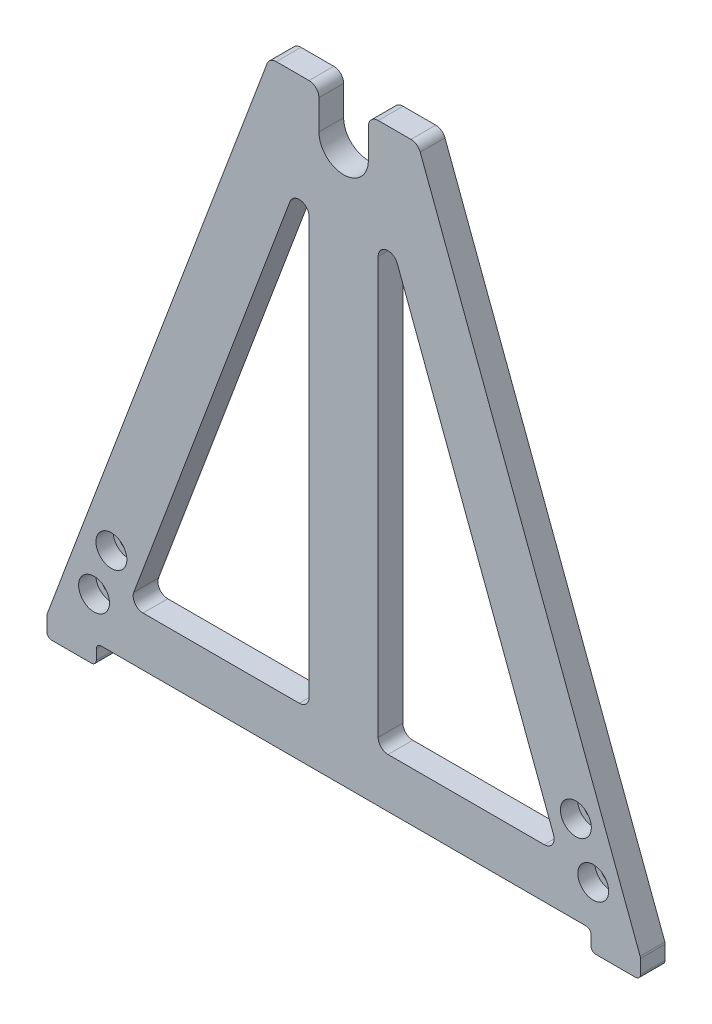
from build123d import *

# Parameters (mm, degrees)
BOSS_EXTRUDE1_DEPTH                            = 6.35
CUT_EXTRUDE1_DEPTH                             = 171.506664093
CUT_EXTRUDE2_DEPTH                             = 171.506664093
FILLET1_R                                      = 2.54
CBORE_FOR_8_SOCKET_HEAD_CAP_SCREW1_D           = 4.9149
CBORE_FOR_8_SOCKET_HEAD_CAP_SCREW1_CBORE_D     = 7.9375
CBORE_FOR_8_SOCKET_HEAD_CAP_SCREW1_CBORE_DEPTH = 4.4196


with BuildPart() as part:
    # Sketch1 → Boss-Extrude1 (new body)
    with BuildSketch(Plane.XY):
        with BuildLine():
            Line((-19.668054922, 150.751853542), (-76.119138056, 0.215631852))
            ThreePointArc((-76.119138056, 0.215631852), (-76.179621009, -0.003695416), (-76.2, -0.230294919))
            Line((-76.2, -0.230294919), (-76.2, -3.81))
            ThreePointArc((-76.2, -3.81), (-75.828025612, -4.708025612), (-74.93, -5.08))
            Line((-74.93, -5.08), (-64.77, -5.08))
            ThreePointArc((-64.77, -5.08), (-63.871974388, -4.708025612), (-63.5, -3.81))
            Line((-63.5, -3.81), (-63.5, -1.27))
            ThreePointArc((-63.5, -1.27), (-63.128025612, -0.371974388), (-62.23, 0))
            Line((-62.23, 0), (62.23, 0))
            ThreePointArc((62.23, 0), (63.128025612, -0.371974388), (63.5, -1.27))
            Line((63.5, -1.27), (63.5, -3.81))
            ThreePointArc((63.5, -3.81), (63.871974388, -4.708025612), (64.77, -5.08))
            Line((64.77, -5.08), (74.93, -5.08))
            ThreePointArc((74.93, -5.08), (75.828025612, -4.708025612), (76.2, -3.81))
            Line((76.2, -3.81), (76.2, -0.230294919))
            ThreePointArc((76.2, -0.230294919), (76.179621009, -0.003695416), (76.119138056, 0.215631852))
            Line((76.119138056, 0.215631852), (19.668054922, 150.751853542))
            ThreePointArc((19.668054922, 150.751853542), (18.736549699, 151.947691069), (17.289778811, 152.4))
            Line((17.289778811, 152.4), (-17.289778811, 152.4))
            ThreePointArc((-17.289778811, 152.4), (-18.736549699, 151.947691069), (-19.668054922, 150.751853542))
        make_face()
    extrude(amount=BOSS_EXTRUDE1_DEPTH)

    # Sketch2 → Cut-Extrude1 (cut, through all)
    with BuildSketch(Plane(origin=(0, 0, 0), x_dir=(-1, 0, 0), z_dir=(0, 0, -1))):
        with BuildLine():
            Line((-8.859145886, 15.24), (-8.859145886, 122.164815439))
            ThreePointArc((-8.859145886, 122.164815439), (-10.94594688, 124.664057457), (-13.777421997, 123.056668981))
            Line((-13.777421997, 123.056668981), (-53.874227787, 16.131853542))
            ThreePointArc((-53.874227787, 16.131853542), (-53.583642745, 13.793229112), (-51.495951676, 12.7))
            Line((-51.495951676, 12.7), (-11.399145886, 12.7))
            ThreePointArc((-11.399145886, 12.7), (-9.603094662, 13.443948776), (-8.859145886, 15.24))
        make_face()
        with BuildLine():
            Line((53.874227787, 16.131853542), (13.777421997, 123.056668981))
            ThreePointArc((13.777421997, 123.056668981), (10.94594688, 124.664057457), (8.859145886, 122.164815439))
            Line((8.859145886, 122.164815439), (8.859145886, 15.24))
            ThreePointArc((8.859145886, 15.24), (9.603094662, 13.443948776), (11.399145886, 12.7))
            Line((11.399145886, 12.7), (51.495951676, 12.7))
            ThreePointArc((51.495951676, 12.7), (53.583642745, 13.793229112), (53.874227787, 16.131853542))
        make_face()
    extrude(amount=-CUT_EXTRUDE1_DEPTH, mode=Mode.SUBTRACT)

    # Sketch3 → Cut-Extrude2 (cut, through all)
    with BuildSketch(Plane(origin=(0, 0, 0), x_dir=(-1, 0, 0), z_dir=(0, 0, -1))):
        with BuildLine():
            Line((-6.35, 142.24), (-6.35, 152.4))
            Line((-6.35, 152.4), (6.35, 152.4))
            Line((6.35, 152.4), (6.35, 142.24))
            ThreePointArc((6.35, 142.24), (0, 135.89), (-6.35, 142.24))
        make_face()
    extrude(amount=-CUT_EXTRUDE2_DEPTH, mode=Mode.SUBTRACT)

    # Fillet1
    fillet1_edges = [part.edges().sort_by_distance(p)[0] for p in [
        (-6.35, 152.4, 3.175),
        (6.35, 152.4, 3.175),
    ]]
    fillet(fillet1_edges, radius=FILLET1_R)

    # CBORE for _8 Socket Head Cap Screw1 (through all)
    with Locations(Plane.XY.offset(6.35)):
        with Locations((-59.619847535, 22.511970393), (-64.079115243, 10.620589838), (59.619847535, 22.511970393), (64.079115243, 10.620589838)):
            CounterBoreHole(CBORE_FOR_8_SOCKET_HEAD_CAP_SCREW1_D / 2, CBORE_FOR_8_SOCKET_HEAD_CAP_SCREW1_CBORE_D / 2, CBORE_FOR_8_SOCKET_HEAD_CAP_SCREW1_CBORE_DEPTH)


solid = part.part
